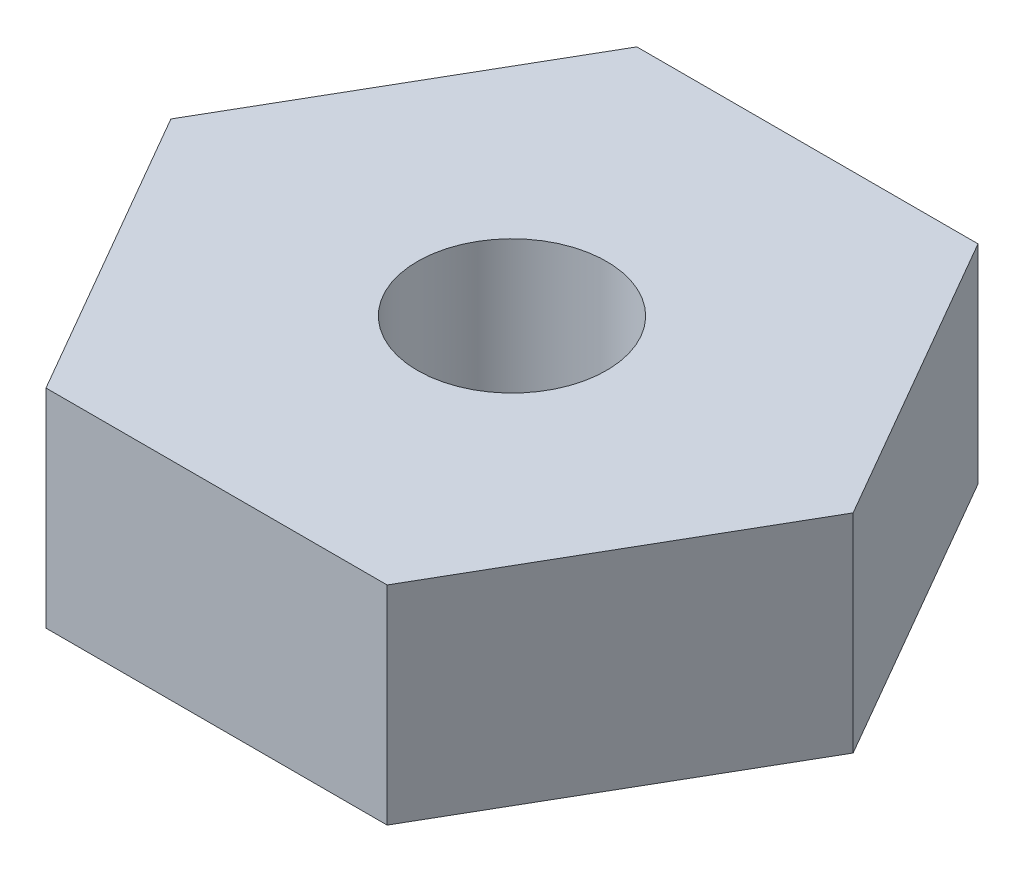
from build123d import *

# Parameters (mm, degrees)
SKETCH1_R           = 0.762
BOSS_EXTRUDE1_DEPTH = 1.6764


with BuildPart() as part:
    # Sketch1 → Boss-Extrude1 (new body)
    with BuildSketch(Plane(origin=(0, 0, 0), x_dir=(1, 0, 0), z_dir=(0, 1, 0))):
        Polygon((-1.374815329, 2.38125), (1.374815329, 2.38125), (2.749630657, 0), (1.374815329, -2.38125), (-1.374815329, -2.38125), (-2.749630657, 0), align=None)
        with Locations(Location((0, 0, 0), (0, 0, 270))):  # turned: the seam where the file's is
            Circle(SKETCH1_R, mode=Mode.SUBTRACT)
    extrude(amount=BOSS_EXTRUDE1_DEPTH)


solid = part.part
